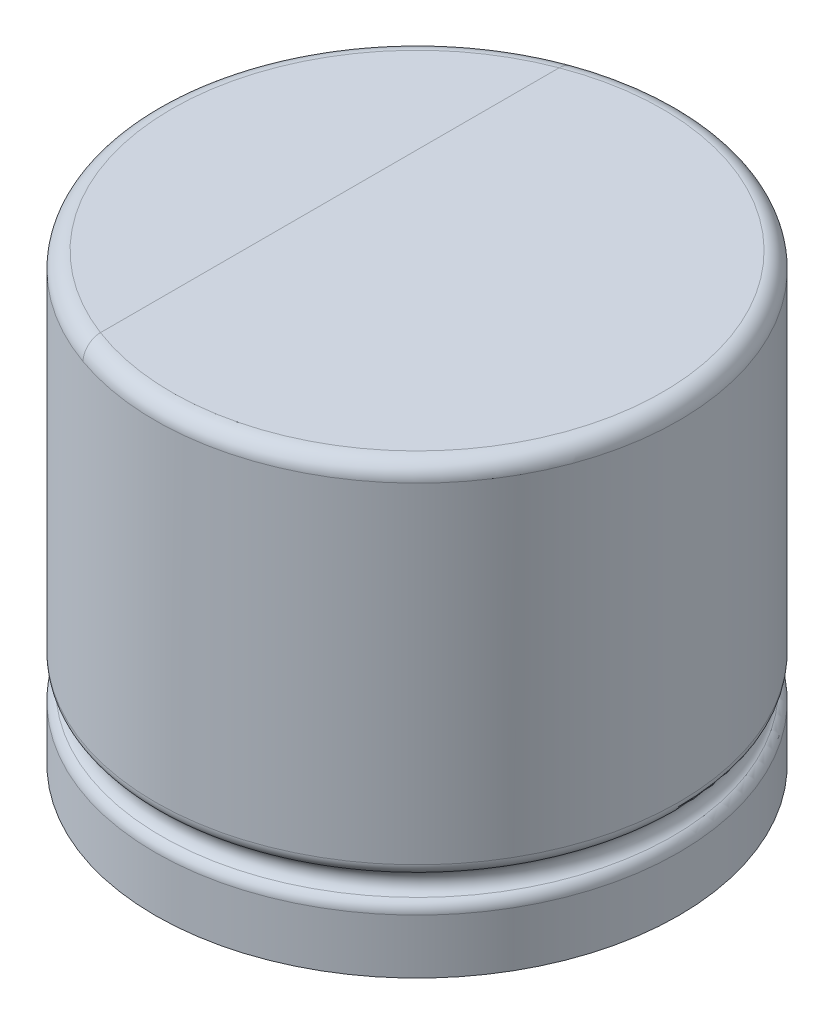
from build123d import *

# Parameters (mm, degrees)
CROQUIS1_W  = 2
CROQUIS1_H  = 3.4
REDONDEO1_R = 0.125


with BuildPart() as part:
    # Croquis1 → Revolución1 (revolve)
    with BuildSketch(Plane.XY):
        with Locations((-1, 2.2)):
            Rectangle(CROQUIS1_W, CROQUIS1_H)
    revolve(axis=Axis((0, 0.5, 0), (0, 1, 0)))

    # Croquis3 → Cortar-Revolución1 (revolve, cut)
    with BuildSketch(Plane.XY):
        with BuildLine():
            Line((-2, 0.916666667), (-2, 1.25))
            ThreePointArc((-2, 1.25), (-1.987108288, 1.201887478), (-1.951887478, 1.166666667))
            ThreePointArc((-1.951887478, 1.166666667), (-1.903774955, 1.083333333), (-1.951887478, 1))
            ThreePointArc((-1.951887478, 1), (-1.987108288, 0.964779189), (-2, 0.916666667))
        make_face()
    revolve(axis=Axis((0, -0.168697536, 0), (0, 1, 0)), mode=Mode.SUBTRACT)

    # Redondeo1
    redondeo1_edges = [part.edges().sort_by_distance(p)[0] for p in [
        (2, 3.9, 0),
    ]]
    fillet(redondeo1_edges, radius=REDONDEO1_R)


solid = part.part
